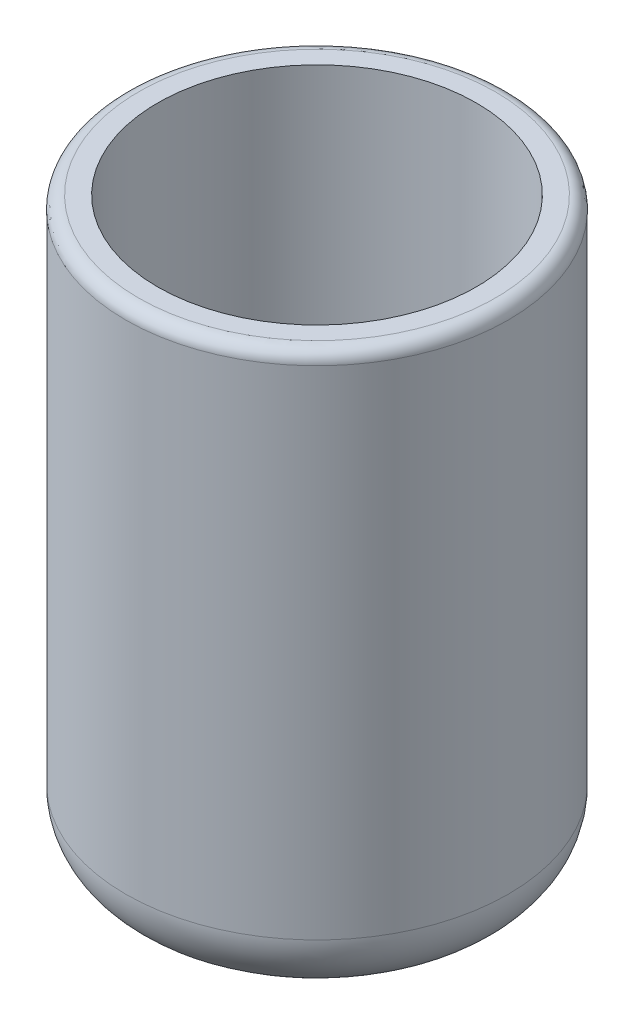
from build123d import *

# Parameters (mm, degrees)
CROQUIS2_R              = 1.5
SALIENTE_EXTRUIR1_DEPTH = 4.5
VACIADO1_T              = -0.25
REDONDEO1_R             = 0.1
REDONDEO2_R             = 0.5


with BuildPart() as part:
    # Croquis2 → Saliente-Extruir1 (new body)
    with BuildSketch(Plane(origin=(0, 0, 0), x_dir=(1, 0, 0), z_dir=(0, 1, 0))):
        with Locations(Location((0, 0, 0), (0, 0, 270))):
            Circle(CROQUIS2_R)
    extrude(amount=SALIENTE_EXTRUIR1_DEPTH)

    # Vaciado1
    vaciado1_openings = [part.faces().sort_by_distance(p)[0] for p in [
        (0, 4.5, 0),
    ]]
    offset(amount=VACIADO1_T, openings=vaciado1_openings, kind=Kind.INTERSECTION)

    # Redondeo1
    redondeo1_edges = [part.edges().sort_by_distance(p)[0] for p in [
        (0, 4.5, -1.5),
    ]]
    fillet(redondeo1_edges, radius=REDONDEO1_R)

    # Redondeo2
    redondeo2_edges = [part.edges().sort_by_distance(p)[0] for p in [
        (0, 0, -1.5),
    ]]
    fillet(redondeo2_edges, radius=REDONDEO2_R)


solid = part.part
